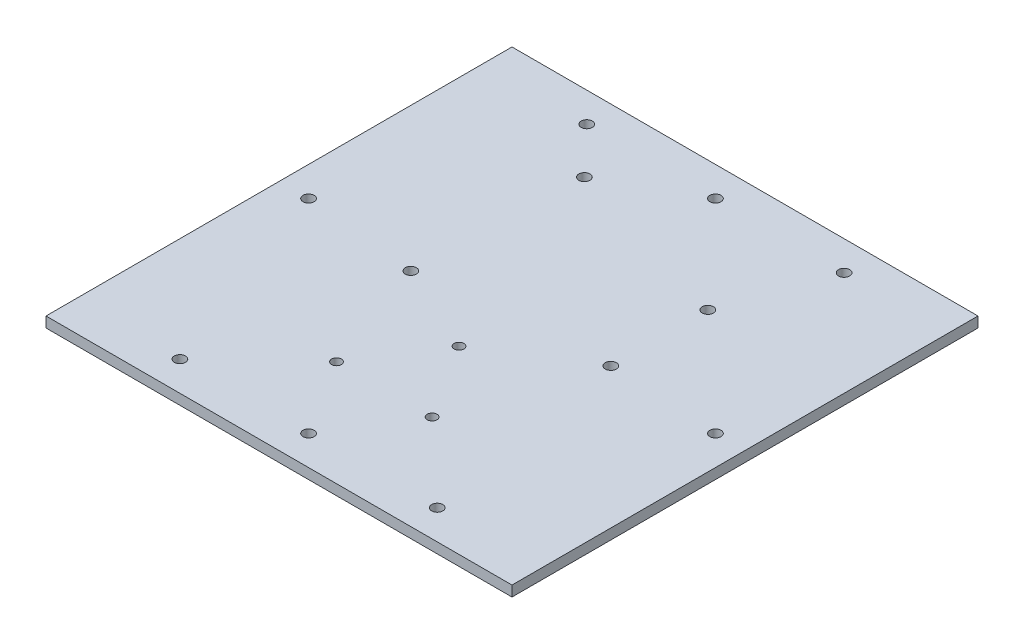
from build123d import *

# Parameters (mm, degrees)
SKETCH2_W           = 134
SKETCH2_H           = 134
SKETCH2_R           = 1.4
SKETCH2_R_2         = 1.6
BOSS_EXTRUDE2_DEPTH = 3


with BuildPart() as part:
    # Sketch2 → Boss-Extrude2 (new body)
    with BuildSketch(Plane(origin=(0, 0, 0), x_dir=(1, 0, 0), z_dir=(0, 1, 0))):
        Rectangle(SKETCH2_W, SKETCH2_H)
        with Locations((-0.080384087, -15.14345336)):
            Circle(SKETCH2_R, mode=Mode.SUBTRACT)
        with Locations((-13.830384087, -36.64345336)):
            Circle(SKETCH2_R, mode=Mode.SUBTRACT)
        with Locations((13.669615913, -36.64345336)):
            Circle(SKETCH2_R, mode=Mode.SUBTRACT)
        with Locations((-24.165395582, 44.984548377)):
            Circle(SKETCH2_R_2, mode=Mode.SUBTRACT)
        with Locations((-25.765395582, -3.315451623)):
            Circle(SKETCH2_R_2, mode=Mode.SUBTRACT)
        with Locations((26.634604418, 29.684548377)):
            Circle(SKETCH2_R_2, mode=Mode.SUBTRACT)
        with Locations((26.634604418, 1.784548377)):
            Circle(SKETCH2_R_2, mode=Mode.SUBTRACT)
        with Locations((0, 58.5)):
            Circle(SKETCH2_R_2, mode=Mode.SUBTRACT)
        with Locations((-58.5, 0)):
            Circle(SKETCH2_R_2, mode=Mode.SUBTRACT)
        with Locations((0, -58.5)):
            Circle(SKETCH2_R_2, mode=Mode.SUBTRACT)
        with Locations((58.5, 0)):
            Circle(SKETCH2_R_2, mode=Mode.SUBTRACT)
        with Locations((-37, 58.5)):
            Circle(SKETCH2_R_2, mode=Mode.SUBTRACT)
        with Locations((37, 58.5)):
            Circle(SKETCH2_R_2, mode=Mode.SUBTRACT)
        with Locations((-37, -58.5)):
            Circle(SKETCH2_R_2, mode=Mode.SUBTRACT)
        with Locations((37, -58.5)):
            Circle(SKETCH2_R_2, mode=Mode.SUBTRACT)
    extrude(amount=BOSS_EXTRUDE2_DEPTH)


solid = part.part
